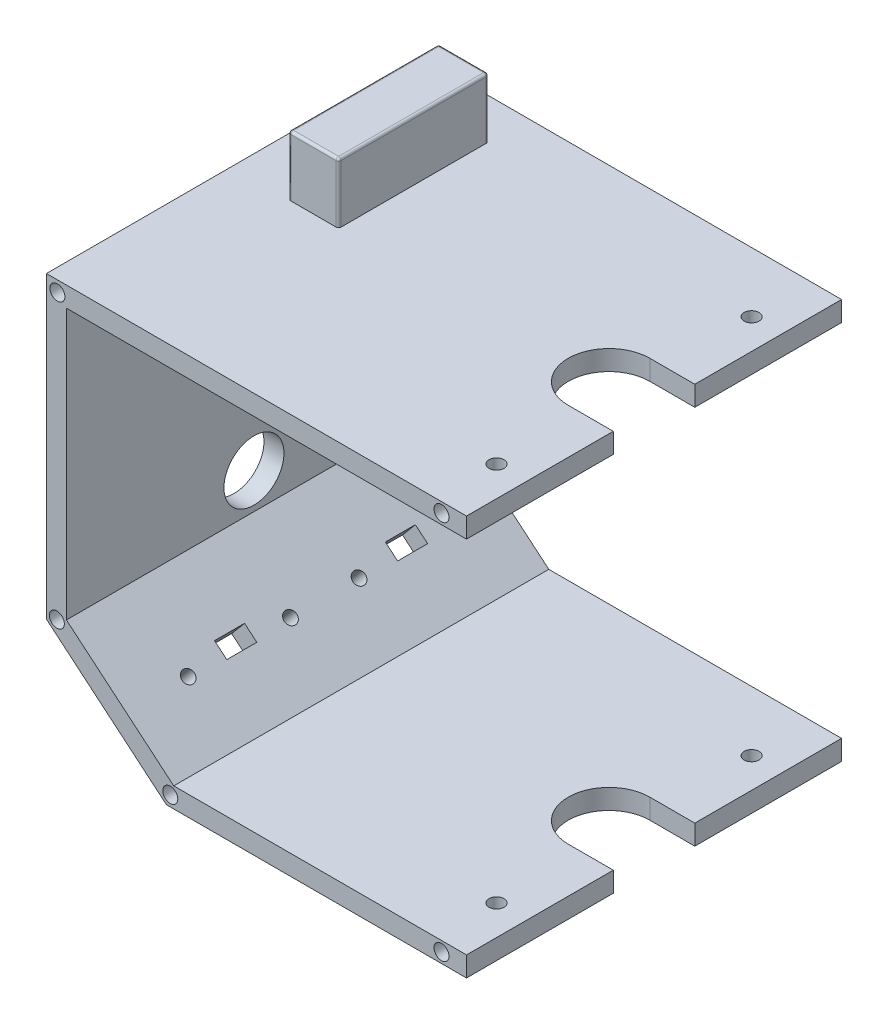
from build123d import *

# Parameters (mm, degrees)
SALIENTE_EXTRUIR1_DEPTH = 75
CROQUIS4_W              = 6
CROQUIS4_H              = 3.2
CROQUIS4_R              = 1.25
CORTAR_EXTRUIR2_DEPTH   = 32
CORTAR_EXTRUIR3_DEPTH   = 81
CROQUIS6_R              = 6
CORTAR_EXTRUIR4_DEPTH   = 85
CROQUIS9_R              = 1.5
CORTAR_EXTRUIR5_DEPTH   = 6
CORTAR_EXTRUIR6_START   = -75
CROQUIS9_2_R            = 1.5
CORTAR_EXTRUIR6_DEPTH   = 6
CROQUIS10_R             = 1.5
CORTAR_EXTRUIR7_DEPTH   = 81
CROQUIS11_W             = 10
CROQUIS11_H             = 30
SALIENTE_EXTRUIR2_DEPTH = 12
CROQUIS13_W             = 9
CROQUIS13_H             = 11
CORTAR_EXTRUIR9_DEPTH   = 29.5
CROQUIS14_W             = 9
CROQUIS14_H             = 12
CORTAR_EXTRUIR10_DEPTH  = 15
CROQUIS15_W             = 10
CROQUIS15_H             = 12
SALIENTE_EXTRUIR3_DEPTH = 0.5
REDONDEO1_R             = 0.5


with BuildPart() as part:
    # Croquis1 → Saliente-Extruir1 (new body)
    with BuildSketch(Plane.XY):
        Polygon((0, 0), (60, 0), (60, 4), (1.455880937, 4), (-20, 22.003621781), (-20, 76), (60, 76), (60, 80), (-24, 80), (-24, 20.138391148), align=None)
    extrude(amount=SALIENTE_EXTRUIR1_DEPTH)

    # Croquis4 → Cortar-Extruir2 (cut)
    with BuildSketch(Plane(origin=(0, 0, 0), x_dir=(0, 0, 1), z_dir=(-0.64278761, -0.766044443, 0))):
        with Locations((52.385, 14.81)):
            Rectangle(CROQUIS4_W, CROQUIS4_H)
        with Locations((18.225, 14.81)):
            Rectangle(CROQUIS4_W, CROQUIS4_H)
        with Locations(Location((8, 13.85, 0), (0, 0, 270))):  # turned: the seam where the file's is
            Circle(CROQUIS4_R)
        with Locations(Location((28.45, 13.85, 0), (0, 0, 270))):  # turned: the seam where the file's is
            Circle(CROQUIS4_R)
        with Locations(Location((42.16, 13.85, 0), (0, 0, 270))):  # turned: the seam where the file's is
            Circle(CROQUIS4_R)
        with Locations(Location((62.61, 13.85, 0), (0, 0, 270))):  # turned: the seam where the file's is
            Circle(CROQUIS4_R)
    extrude(amount=-CORTAR_EXTRUIR2_DEPTH, mode=Mode.SUBTRACT)

    # Croquis5 → Cortar-Extruir3 (cut, through all)
    with BuildSketch(Plane(origin=(0, 80, 0), x_dir=(1, 0, 0), z_dir=(0, 1, 0))):
        with BuildLine():
            Line((60, -29.35), (51, -29.35))
            ThreePointArc((51, -29.35), (42.85, -37.5), (51, -45.65))
            Line((51, -45.65), (60, -45.65))
            Line((60, -45.65), (60, -29.35))
        make_face()
    extrude(amount=-CORTAR_EXTRUIR3_DEPTH, mode=Mode.SUBTRACT)

    # Croquis6 → Cortar-Extruir4 (cut, through all)
    with BuildSketch(Plane.ZY.offset(24)):
        with Locations(Location((37.5, 29.138391148, 0), (0, 0, 270))):  # turned: the seam where the file's is
            Circle(CROQUIS6_R)
    extrude(amount=-CORTAR_EXTRUIR4_DEPTH, mode=Mode.SUBTRACT)

    # Croquis9 → Cortar-Extruir5 (cut)
    with BuildSketch(Plane.XY.offset(75)):
        with Locations((-21.807968978, 77.807968978)):
            Circle(CROQUIS9_R)
        with Locations((-21.91549209, 21.11041315)):
            Circle(CROQUIS9_R)
        with Locations((0.764337492, 2.1)):
            Circle(CROQUIS9_R)
        with Locations((55, 78)):
            Circle(CROQUIS9_R)
        with Locations((55, 2)):
            Circle(CROQUIS9_R)
    extrude(amount=-CORTAR_EXTRUIR5_DEPTH, mode=Mode.SUBTRACT)

    # Croquis9_2 → Cortar-Extruir6 (cut)
    with BuildSketch(Plane.XY.offset(75).offset(CORTAR_EXTRUIR6_START)):
        with Locations((-21.807968978, 77.807968978)):
            Circle(CROQUIS9_2_R)
        with Locations((-21.91549209, 21.11041315)):
            Circle(CROQUIS9_2_R)
        with Locations((0.764337492, 2.1)):
            Circle(CROQUIS9_2_R)
        with Locations((55, 78)):
            Circle(CROQUIS9_2_R)
        with Locations((55, 2)):
            Circle(CROQUIS9_2_R)
    extrude(amount=CORTAR_EXTRUIR6_DEPTH, mode=Mode.SUBTRACT)

    # Croquis10 → Cortar-Extruir7 (cut, through all)
    with BuildSketch(Plane(origin=(0, 80, 0), x_dir=(1, 0, 0), z_dir=(0, 1, 0))):
        with Locations(Location((54, -63, 0), (0, 0, 270))):  # turned: the seam where the file's is
            Circle(CROQUIS10_R)
        with Locations(Location((54, -12, 0), (0, 0, 270))):  # turned: the seam where the file's is
            Circle(CROQUIS10_R)
    extrude(amount=-CORTAR_EXTRUIR7_DEPTH, mode=Mode.SUBTRACT)

    # Croquis11 → Saliente-Extruir2 (add)
    with BuildSketch(Plane(origin=(0, 80, 0), x_dir=(1, 0, 0), z_dir=(0, 1, 0))):
        with Locations((-7.574441985, -23)):
            Rectangle(CROQUIS11_W, CROQUIS11_H)
    extrude(amount=SALIENTE_EXTRUIR2_DEPTH)

    # Croquis13 → Cortar-Extruir9 (cut)
    with BuildSketch(Plane.XY.offset(38)):
        with Locations((-7.574441985, 86)):
            Rectangle(CROQUIS13_W, CROQUIS13_H)
    extrude(amount=-CORTAR_EXTRUIR9_DEPTH, mode=Mode.SUBTRACT)

    # Croquis14 → Cortar-Extruir10 (cut)
    with BuildSketch(Plane(origin=(0, 80.5, 0), x_dir=(1, 0, 0), z_dir=(0, 1, 0))):
        with Locations((-7.574441985, -31.5)):
            Rectangle(CROQUIS14_W, CROQUIS14_H)
    extrude(amount=-CORTAR_EXTRUIR10_DEPTH, mode=Mode.SUBTRACT)

    # Croquis15 → Saliente-Extruir3 (add)
    with BuildSketch(Plane.XY.offset(38)):
        with Locations((-7.574441985, 86)):
            Rectangle(CROQUIS15_W, CROQUIS15_H)
    extrude(amount=-SALIENTE_EXTRUIR3_DEPTH)

    # Redondeo1
    redondeo1_edges = [part.edges().sort_by_distance(p)[0] for p in [
        (-12.574441985, 86, 8),
        (-12.574441985, 86, 38),
        (-2.574441985, 86, 38),
        (-2.574441985, 86, 8),
        (-12.574441985, 92, 23),
        (-7.574441985, 92, 38),
        (-2.574441985, 92, 23),
        (-7.574441985, 92, 8),
    ]]
    fillet(redondeo1_edges, radius=REDONDEO1_R)


solid = part.part
